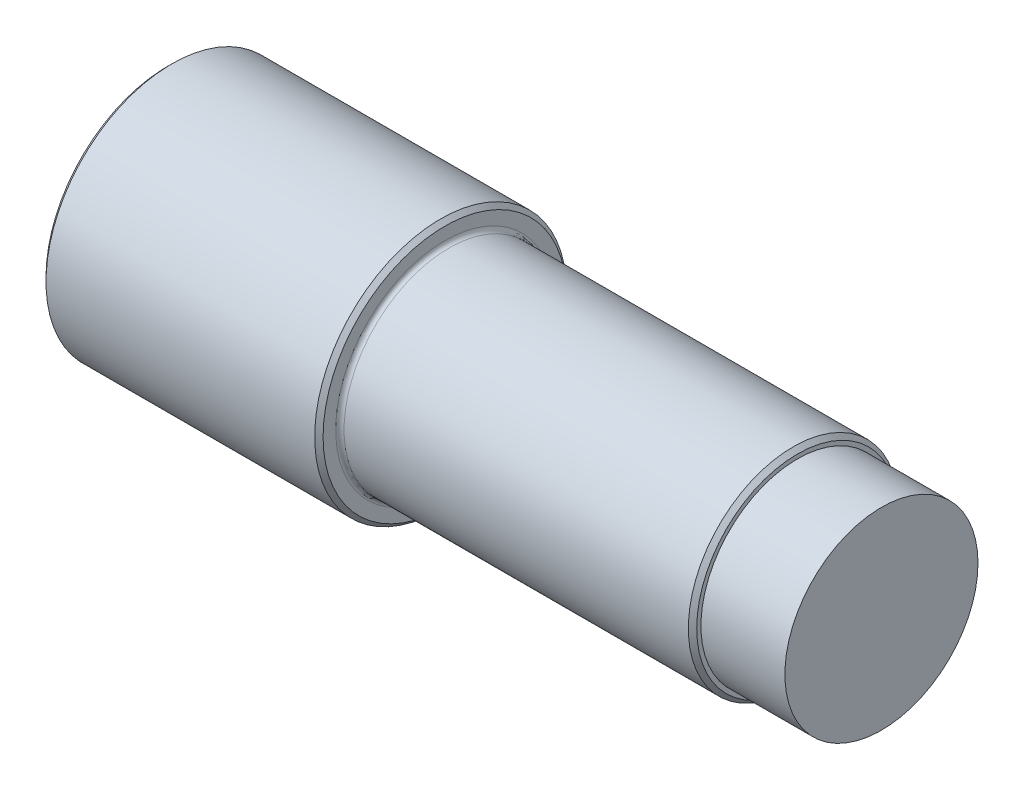
from build123d import *

# Parameters (mm, degrees)
SKETCH_1_R      = 15
EXTRUDE_1_DEPTH = 33
SKETCH_2_R      = 12.5
EXTRUDE_2_DEPTH = 42
FILLET_1_R      = 0.5
CHAMFER_1_SIZE  = 0.5
SKETCH_3_R      = 11.5
EXTRUDE_3_DEPTH = 10


with BuildPart() as part:
    # 草图1 → 凸台-拉伸1 (new body)
    with BuildSketch(Plane(origin=(0, 0, 0), x_dir=(0, 0, -1), z_dir=(1, 0, 0))):
        Circle(SKETCH_1_R)
    extrude(amount=EXTRUDE_1_DEPTH)

    # 草图2 → 凸台-拉伸2 (add)
    with BuildSketch(Plane(origin=(33, 0, 0), x_dir=(0, 0, -1), z_dir=(1, 0, 0))):
        Circle(SKETCH_2_R)
    extrude(amount=EXTRUDE_2_DEPTH)

    # 圆角1
    fillet_1_edges = [part.edges().sort_by_distance(p)[0] for p in [
        (33, 0, 12.5),
    ]]
    fillet(fillet_1_edges, radius=FILLET_1_R)

    # 倒角1
    chamfer_1_edges = [part.edges().sort_by_distance(p)[0] for p in [
        (0, 0, 15),
        (33, 0, 15),
        (75, 0, 12.5),
    ]]
    chamfer(chamfer_1_edges, length=CHAMFER_1_SIZE)

    # 草图3 → 凸台-拉伸3 (add)
    with BuildSketch(Plane(origin=(75, 0, 0), x_dir=(0, 0, -1), z_dir=(1, 0, 0))):
        Circle(SKETCH_3_R)
    extrude(amount=EXTRUDE_3_DEPTH)


solid = part.part
